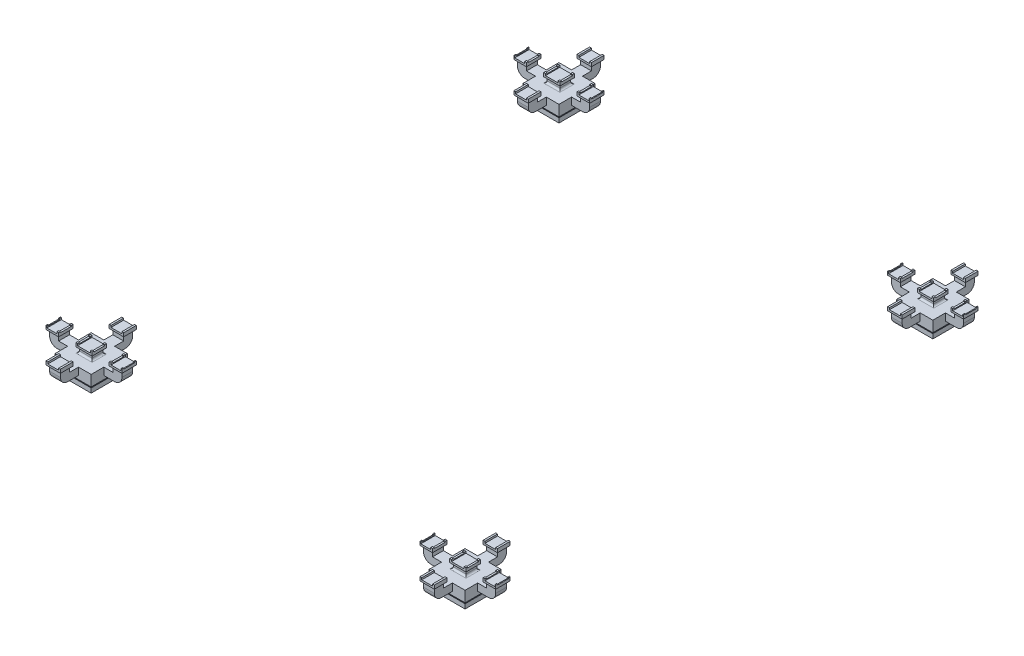
from build123d import *

# Parameters (mm, degrees)
SKETCH_1_W               = 50
SKETCH_1_H               = 50
EXTRUDE_1_DEPTH          = 70
SKETCH_2_W               = 150
SKETCH_2_H               = 150
SKETCH_3_W               = 200
SKETCH_3_H               = 200
SKETCH_4_W               = 200
SKETCH_4_H               = 200
EXTRUDE_2_DEPTH          = 20
SKETCH_5_W               = 70
SKETCH_5_H               = 70
EXTRUDE_3_DEPTH          = 40
SKETCH_6_W               = 400
SKETCH_6_H               = 60
EXTRUDE_4_DEPTH          = 40
SKETCH_7_W               = 50
SKETCH_7_H               = 60
SKETCH_7_W_2             = 70
EXTRUDE_6_DEPTH          = 20
SKETCH_8_W               = 65
SKETCH_8_H               = 60
CUT_EXTRUDE_1_DEPTH      = 20
FILLET_1_R               = 40
SKETCH_10_W              = 50
SKETCH_10_H              = 60
SKETCH_9_W               = 70
SKETCH_9_H               = 80
SKETCH_12_W              = 70
SKETCH_12_H              = 80
EXTRUDE_7_DEPTH          = 10
SKETCH_13_W              = 10
SKETCH_13_H              = 80
SKETCH_13_W_2            = 5
EXTRUDE_8_DEPTH          = 10
SKETCH_15_W              = 60
SKETCH_15_H              = 400
EXTRUDE_9_DEPTH          = 40
SKETCH_16_W              = 60
SKETCH_16_H              = 50
EXTRUDE_10_DEPTH         = 20
SKETCH_18_W              = 80
SKETCH_18_H              = 70
SKETCH_17_W              = 60
SKETCH_17_H              = 50
SKETCH_19_W              = 80
SKETCH_19_H              = 70
EXTRUDE_12_DEPTH         = 10
SKETCH_20_W              = 10
SKETCH_20_H              = 70
EXTRUDE_13_DEPTH         = 10
FILLET_3_R               = 10
SKETCH_21_W              = 60
SKETCH_21_H              = 60
EXTRUDE_14_DEPTH         = 20
FILLET_4_R               = 10
SKETCH_22_W              = 70
SKETCH_22_H              = 60
SKETCH_23_W              = 90
SKETCH_23_H              = 80
EXTRUDE_15_DEPTH         = 10
SKETCH_25_W              = 10
SKETCH_25_H              = 80
EXTRUDE_16_DEPTH         = 10
SKETCH_26_W              = 420
SKETCH_26_H              = 60
CUT_EXTRUDE_2_DEPTH      = 5
FILLET_5_R               = 40
SCALE_1_SCALE            = 2
SKETCH_30_W              = 100
SKETCH_30_H              = 100
SKETCH_30_W_2            = 80
SKETCH_30_H_2            = 80
CUT_EXTRUDE_4_DEPTH      = 140
SKETCH_31_W              = 80
SKETCH_31_H              = 80
EXTRUDE_18_DEPTH         = 10
SKETCH_32_W              = 300
SKETCH_32_H              = 300
SKETCH_32_W_2            = 80
SKETCH_32_H_2            = 80
EXTRUDE_19_DEPTH         = 50
PATTERN_LINEAR_1_COUNT   = 2
PATTERN_LINEAR_1_PITCH   = 5180
PATTERN_LINEAR_1_2_COUNT = 2
PATTERN_LINEAR_1_2_PITCH = 4140


with BuildPart() as part:
    # 草图1 → 凸台-拉伸1 (new body)
    with BuildSketch(Plane(origin=(0, 0, 0), x_dir=(1, 0, 0), z_dir=(0, 1, 0))):
        with Locations((25, 25)):
            Rectangle(SKETCH_1_W, SKETCH_1_H)
    extrude(amount=EXTRUDE_1_DEPTH)

    # 草图2 → 放样2 section 0
    with BuildSketch(Plane(origin=(0, 70, 0), x_dir=(1, 0, 0), z_dir=(0, 1, 0))):
        with Locations((25, 25)):
            Rectangle(SKETCH_2_W, SKETCH_2_H)
    # 草图3 → 放样2 section 1
    with BuildSketch(Plane(origin=(0, 100, 0), x_dir=(1, 0, 0), z_dir=(0, 1, 0))):
        with Locations((25, 25)):
            Rectangle(SKETCH_3_W, SKETCH_3_H)
    loft()

    # 草图4 → 凸台-拉伸2 (add)
    with BuildSketch(Plane(origin=(0, 100, 0), x_dir=(1, 0, 0), z_dir=(0, 1, 0))):
        with Locations((25, 25)):
            Rectangle(SKETCH_4_W, SKETCH_4_H)
    extrude(amount=EXTRUDE_2_DEPTH)

    # 草图5 → 凸台-拉伸3 (add)
    with BuildSketch(Plane(origin=(0, 120, 0), x_dir=(1, 0, 0), z_dir=(0, 1, 0))):
        with Locations((-40, -40)):
            Rectangle(SKETCH_5_W, SKETCH_5_H)
        with Locations((90, -40)):
            Rectangle(SKETCH_5_W, SKETCH_5_H)
        with Locations((90, 90)):
            Rectangle(SKETCH_5_W, SKETCH_5_H)
        with Locations((-40, 90)):
            Rectangle(SKETCH_5_W, SKETCH_5_H)
    extrude(amount=EXTRUDE_3_DEPTH)

    # 草图6 → 凸台-拉伸4 (add)
    with BuildSketch(Plane(origin=(0, 120, 0), x_dir=(1, 0, 0), z_dir=(0, 1, 0))):
        with Locations((25, 25)):
            Rectangle(SKETCH_6_W, SKETCH_6_H)
    extrude(amount=EXTRUDE_4_DEPTH)

    # 草图7 → 凸台-拉伸6 (add)
    with BuildSketch(Plane(origin=(0, 160, 0), x_dir=(1, 0, 0), z_dir=(0, 1, 0))):
        with Locations((200, 25)):
            Rectangle(SKETCH_7_W, SKETCH_7_H)
        with Locations((-150, 25)):
            Rectangle(SKETCH_7_W, SKETCH_7_H)
        with Locations((90, 25)):
            Rectangle(SKETCH_7_W_2, SKETCH_7_H)
        with Locations((-40, 25)):
            Rectangle(SKETCH_7_W_2, SKETCH_7_H)
    extrude(amount=EXTRUDE_6_DEPTH)

    # 草图8 → 切除-拉伸1 (cut)
    with BuildSketch(Plane(origin=(0, 180, 0), x_dir=(1, 0, 0), z_dir=(0, 1, 0))):
        with Locations((-42.5, 25)):
            Rectangle(SKETCH_8_W, SKETCH_8_H)
        with Locations((92.5, 25)):
            Rectangle(SKETCH_8_W, SKETCH_8_H)
    extrude(amount=-CUT_EXTRUDE_1_DEPTH, mode=Mode.SUBTRACT)

    # 圆角1
    fillet_1_edges = [part.edges().sort_by_distance(p)[0] for p in [
        (-175, 120, -25),
        (225, 120, -25),
    ]]
    fillet(fillet_1_edges, radius=FILLET_1_R)

    # 草图10 → 放样3 section 0
    with BuildSketch(Plane(origin=(0, 180, 0), x_dir=(1, 0, 0), z_dir=(0, 1, 0))):
        with Locations((200, 25)):
            Rectangle(SKETCH_10_W, SKETCH_10_H)
    # 草图9 → 放样3 section 1
    with BuildSketch(Plane(origin=(0, 190, 0), x_dir=(1, 0, 0), z_dir=(0, 1, 0))):
        with Locations((200, 25)):
            Rectangle(SKETCH_9_W, SKETCH_9_H)
    loft_3 = loft()

    # 草图12 → 凸台-拉伸7 (add)
    with BuildSketch(Plane(origin=(0, 190, 0), x_dir=(1, 0, 0), z_dir=(0, 1, 0))):
        with Locations((200, 25)):
            Rectangle(SKETCH_12_W, SKETCH_12_H)
    extrude_7 = extrude(amount=EXTRUDE_7_DEPTH)

    # 草图13 → 凸台-拉伸8 (add)
    with BuildSketch(Plane(origin=(0, 200, 0), x_dir=(1, 0, 0), z_dir=(0, 1, 0))):
        with Locations((170, 25)):
            Rectangle(SKETCH_13_W, SKETCH_13_H)
        with Locations((232.5, 25)):
            Rectangle(SKETCH_13_W_2, SKETCH_13_H)
    extrude_8 = extrude(amount=EXTRUDE_8_DEPTH)

    # 镜向2: 放样3, 凸台-拉伸7, 凸台-拉伸8 across plane
    add(loft_3.mirror(Plane(origin=(25, 0, 0), x_dir=(0, 0, 1), z_dir=(1, 0, 0))))
    add(extrude_7.mirror(Plane(origin=(25, 0, 0), x_dir=(0, 0, 1), z_dir=(1, 0, 0))))
    add(extrude_8.mirror(Plane(origin=(25, 0, 0), x_dir=(0, 0, 1), z_dir=(1, 0, 0))))

    # 草图15 → 凸台-拉伸9 (add)
    with BuildSketch(Plane(origin=(0, 120, 0), x_dir=(1, 0, 0), z_dir=(0, 1, 0))):
        with Locations((25, 25)):
            Rectangle(SKETCH_15_W, SKETCH_15_H)
    extrude(amount=EXTRUDE_9_DEPTH)

    # 草图16 → 凸台-拉伸10 (add)
    with BuildSketch(Plane(origin=(0, 160, 0), x_dir=(1, 0, 0), z_dir=(0, 1, 0))):
        with Locations((25, -150)):
            Rectangle(SKETCH_16_W, SKETCH_16_H)
        with Locations((25, 200)):
            Rectangle(SKETCH_16_W, SKETCH_16_H)
    extrude(amount=EXTRUDE_10_DEPTH)

    # 草图18 → 放样4 section 0
    with BuildSketch(Plane(origin=(0, 190, 0), x_dir=(1, 0, 0), z_dir=(0, 1, 0))):
        with Locations((25, -150)):
            Rectangle(SKETCH_18_W, SKETCH_18_H)
    # 草图17 → 放样4 section 1
    with BuildSketch(Plane(origin=(0, 180, 0), x_dir=(1, 0, 0), z_dir=(0, 1, 0))):
        with Locations((25, -150)):
            Rectangle(SKETCH_17_W, SKETCH_17_H)
    loft_4 = loft()

    # 草图19 → 凸台-拉伸12 (add)
    with BuildSketch(Plane(origin=(0, 190, 0), x_dir=(1, 0, 0), z_dir=(0, 1, 0))):
        with Locations((25, -150)):
            Rectangle(SKETCH_19_W, SKETCH_19_H)
    extrude_12 = extrude(amount=EXTRUDE_12_DEPTH)

    # 草图20 → 凸台-拉伸13 (add)
    with BuildSketch(Plane(origin=(0, 200, 0), x_dir=(1, 0, 0), z_dir=(0, 1, 0))):
        with Locations((-10, -150)):
            Rectangle(SKETCH_20_W, SKETCH_20_H)
        with Locations((60, -150)):
            Rectangle(SKETCH_20_W, SKETCH_20_H)
    extrude_13 = extrude(amount=EXTRUDE_13_DEPTH)

    # 镜向3: 放样4, 凸台-拉伸12, 凸台-拉伸13 across plane
    add(loft_4.mirror(Plane.XY.offset(-25)))
    add(extrude_12.mirror(Plane.XY.offset(-25)))
    add(extrude_13.mirror(Plane.XY.offset(-25)))

    # 圆角3
    fillet_3_edges = [part.edges().sort_by_distance(p)[0] for p in [
        (-10, 160, -25),
        (60, 160, -25),
    ]]
    fillet(fillet_3_edges, radius=FILLET_3_R)

    # 草图21 → 凸台-拉伸14 (add)
    with BuildSketch(Plane(origin=(0, 160, 0), x_dir=(1, 0, 0), z_dir=(0, 1, 0))):
        with Locations((25, 25)):
            Rectangle(SKETCH_21_W, SKETCH_21_H)
    extrude(amount=EXTRUDE_14_DEPTH)

    # 圆角4
    fillet_4_edges = [part.edges().sort_by_distance(p)[0] for p in [
        (25, 160, -55),
        (25, 160, 5),
    ]]
    fillet(fillet_4_edges, radius=FILLET_4_R)

    # 草图22 → 放样5 section 0
    with BuildSketch(Plane(origin=(0, 180, 0), x_dir=(1, 0, 0), z_dir=(0, 1, 0))):
        with Locations((25, 25)):
            Rectangle(SKETCH_22_W, SKETCH_22_H)
    # 草图23 → 放样5 section 1
    with BuildSketch(Plane(origin=(0, 190, 0), x_dir=(1, 0, 0), z_dir=(0, 1, 0))):
        with Locations((25, 25)):
            Rectangle(SKETCH_23_W, SKETCH_23_H)
    loft()

    # 草图24 → 凸台-拉伸15 (add)
    with BuildSketch(Plane(origin=(0, 190, 0), x_dir=(1, 0, 0), z_dir=(0, 1, 0))):
        Polygon((-20, 65), (-20, -15), (-10, -15), (60, -15), (70, -15), (70, 65), (60, 65), (-10, 65), align=None)
    extrude(amount=EXTRUDE_15_DEPTH)

    # 草图25 → 凸台-拉伸16 (add)
    with BuildSketch(Plane(origin=(0, 200, 0), x_dir=(1, 0, 0), z_dir=(0, 1, 0))):
        with Locations((-15, 25)):
            Rectangle(SKETCH_25_W, SKETCH_25_H)
        with Locations((65, 25)):
            Rectangle(SKETCH_25_W, SKETCH_25_H)
    extrude(amount=EXTRUDE_16_DEPTH)

    # 草图26 → 切除-拉伸2 (cut)
    with BuildSketch(Plane(origin=(0, 210, 0), x_dir=(1, 0, 0), z_dir=(0, 1, 0))):
        with Locations((25, 25)):
            Rectangle(SKETCH_26_W, SKETCH_26_H)
    extrude(amount=-CUT_EXTRUDE_2_DEPTH, mode=Mode.SUBTRACT)

    # 圆角5
    fillet_5_edges = [part.edges().sort_by_distance(p)[0] for p in [
        (25, 120, -225),
        (25, 120, 175),
    ]]
    fillet(fillet_5_edges, radius=FILLET_5_R)


with BuildPart() as part_1:
    # 缩放比例1: scaled about (0, 0, 0)
    add(part.part.scale(SCALE_1_SCALE))

    # 草图30 → 切除-拉伸4 (cut)
    with BuildSketch(Plane.XZ):
        with Locations((50, -50)):
            Rectangle(SKETCH_30_W, SKETCH_30_H)
        with Locations((50, -50)):
            Rectangle(SKETCH_30_W_2, SKETCH_30_H_2, mode=Mode.SUBTRACT)
    extrude(amount=-CUT_EXTRUDE_4_DEPTH, mode=Mode.SUBTRACT)

    # 草图31 → 凸台-拉伸18 (add)
    with BuildSketch(Plane.XZ):
        with Locations((50, -50)):
            Rectangle(SKETCH_31_W, SKETCH_31_H)
    extrude(amount=EXTRUDE_18_DEPTH)

    # 草图32 → 凸台-拉伸19 (add)
    with BuildSketch(Plane.XZ.offset(-140)):
        with Locations((50, -50)):
            Rectangle(SKETCH_32_W, SKETCH_32_H)
        with Locations((50, -50)):
            Rectangle(SKETCH_32_W_2, SKETCH_32_H_2, mode=Mode.SUBTRACT)
    extrude(amount=EXTRUDE_19_DEPTH)


with BuildPart() as pattern_linear_1_1:
    # 阵列(线性)1: pattern copy
    add(part_1.part.moved(Location(Vector(0, 0, -1) * (1 * PATTERN_LINEAR_1_PITCH))))


with BuildPart() as pattern_linear_1_2_1:
    # Pattern Linear 1 2: pattern copy
    add(part_1.part.moved(Location(Vector(1, 0, 0) * (1 * PATTERN_LINEAR_1_2_PITCH))))


with BuildPart() as pattern_linear_1_2_2:
    # Pattern Linear 1 2: pattern copy
    add(pattern_linear_1_1.part.moved(Location(Vector(1, 0, 0) * (1 * PATTERN_LINEAR_1_2_PITCH))))


solid = Compound([part_1.part, pattern_linear_1_1.part, pattern_linear_1_2_1.part, pattern_linear_1_2_2.part])
